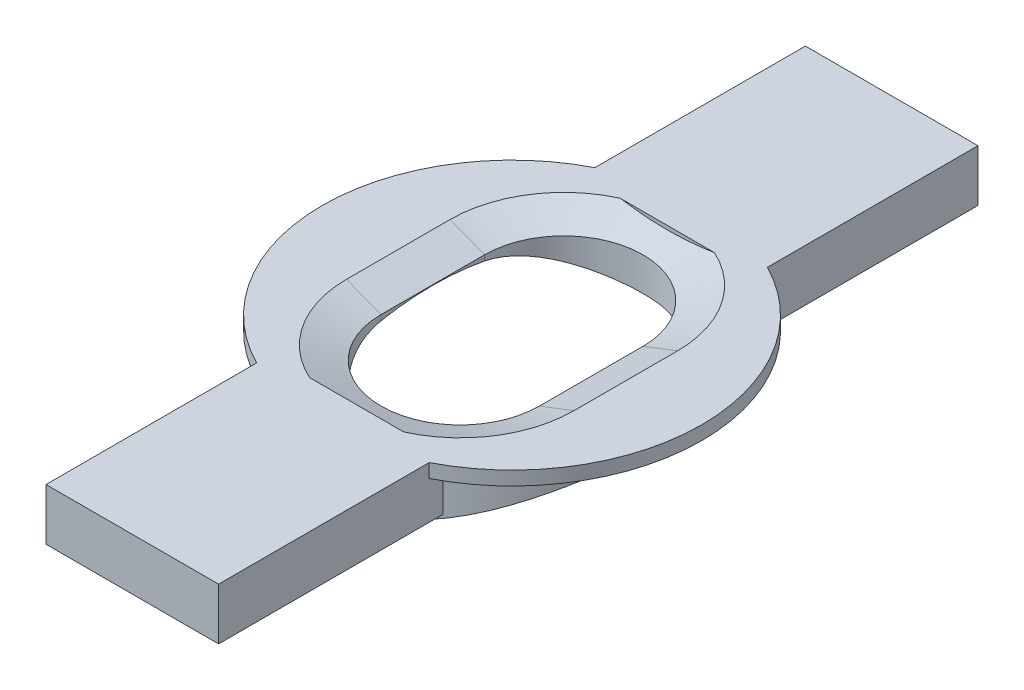
from build123d import *

# Parameters (mm, degrees)
SKETCH1_R               = 5
BOSS_EXTRUDE1_DEPTH     = 5
SKETCH2_R               = 5.5
BOSS_EXTRUDE2_DEPTH     = 0.4
CUT_EXTRUDE1_DEPTH      = 6.4
SKETCH5_R               = 8
CUT_EXTRUDE2_DEPTH      = 6.5
CUT_EXTRUDE2_DEPTH_BACK = 6.5
CHAMFER4_SIZE           = 1
CHAMFER4_SIZE2          = 0.383864035
SKETCH7_W               = 5
SKETCH7_H               = 6.5
BOSS_EXTRUDE4_DEPTH     = 1.5


with BuildPart() as part:
    # Sketch1 → Boss-Extrude1 (new body)
    with BuildSketch(Plane(origin=(0, 0, 0), x_dir=(1, 0, 0), z_dir=(0, 1, 0))):
        Circle(SKETCH1_R)
    extrude(amount=BOSS_EXTRUDE1_DEPTH)

    # Sketch2 → Boss-Extrude2 (add)
    with BuildSketch(Plane(origin=(0, 5, 0), x_dir=(1, 0, 0), z_dir=(0, 1, 0))):
        Circle(SKETCH2_R)
    extrude(amount=BOSS_EXTRUDE2_DEPTH)

    # Sketch4 → Cut-Extrude1 (cut, through all)
    with BuildSketch(Plane(origin=(0, 5.4, 0), x_dir=(1, 0, 0), z_dir=(0, 1, 0))):
        with BuildLine():
            Line((2.295250379, 1.5), (2.295250379, -1.5))
            ThreePointArc((2.295250379, -1.5), (0, -3.795250379), (-2.295250379, -1.5))
            Line((-2.295250379, -1.5), (-2.295250379, 1.5))
            ThreePointArc((-2.295250379, 1.5), (0, 3.795250379), (2.295250379, 1.5))
        make_face()
    extrude(amount=-CUT_EXTRUDE1_DEPTH, mode=Mode.SUBTRACT)

    # Sketch5 → Cut-Extrude2 (cut, two sides)
    with BuildSketch(Plane(origin=(0, 0, 0), x_dir=(0, 0, -1), z_dir=(1, 0, 0))) as cut_extrude2_sk:
        with Locations((0, -3)):
            Circle(SKETCH5_R)
    extrude(amount=CUT_EXTRUDE2_DEPTH, mode=Mode.SUBTRACT)
    extrude(cut_extrude2_sk.sketch, amount=-CUT_EXTRUDE2_DEPTH_BACK, mode=Mode.SUBTRACT)

    # Chamfer4
    chamfer4_edges = [part.edges().sort_by_distance(p)[0] for p in [
        (0, 5.4, -3.795250379),
        (-2.295250379, 5.4, 0),
        (0, 5.4, 3.795250379),
        (2.295250379, 5.4, 0),
    ]]
    chamfer4_side = [part.faces().sort_by_distance(p)[0] for p in [
        (-5.344436508, 5.4, 0),
    ]]
    chamfer(chamfer4_edges, length=CHAMFER4_SIZE, length2=CHAMFER4_SIZE2, reference=chamfer4_side[0])

    # Sketch7 → Boss-Extrude4 (add)
    with BuildSketch(Plane(origin=(0, 5.4, 0), x_dir=(1, 0, 0), z_dir=(0, 1, 0))):
        with Locations((0, 7.75)):
            Rectangle(SKETCH7_W, SKETCH7_H)
        with Locations((0, -7.75)):
            Rectangle(SKETCH7_W, SKETCH7_H)
    extrude(amount=-BOSS_EXTRUDE4_DEPTH)


solid = part.part
